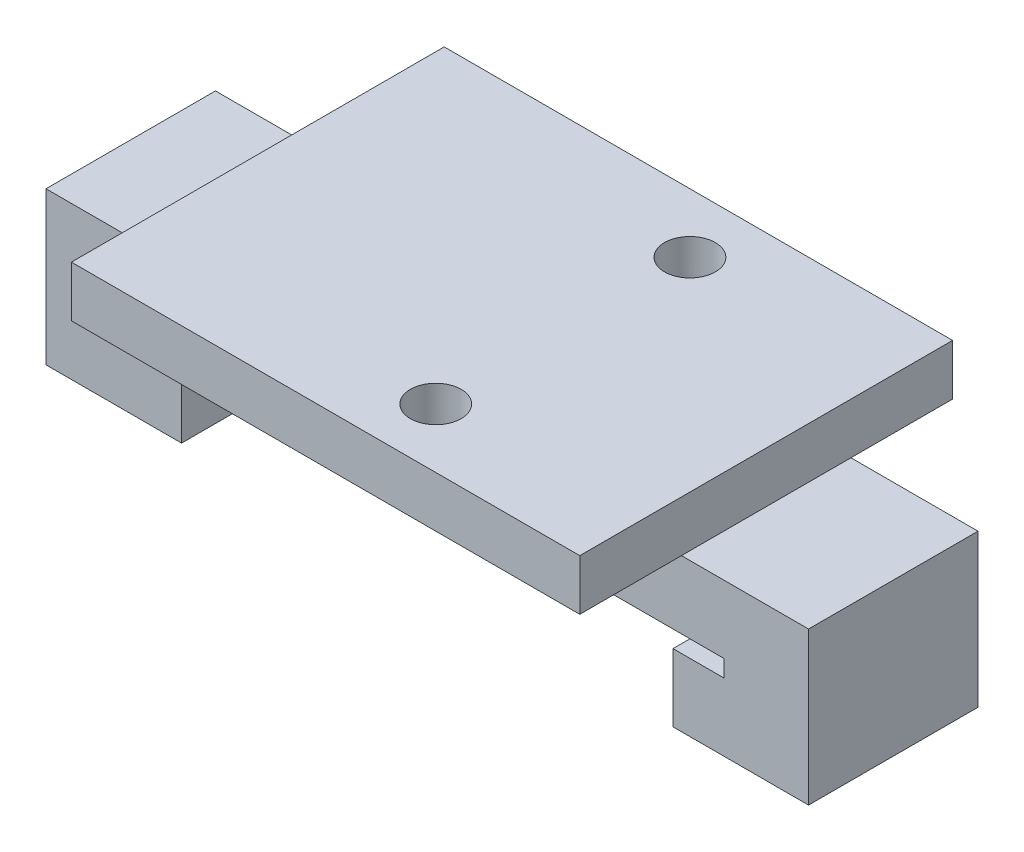
from build123d import *

# Parameters (mm, degrees)
BOSS_EXTRUDE1_DEPTH = 10
SKETCH3_W           = 30
SKETCH3_H           = 22
BOSS_EXTRUDE2_DEPTH = 3
SKETCH4_R           = 1.5
CUT_EXTRUDE1_DEPTH  = 5


with BuildPart() as part:
    # Sketch2 → Boss-Extrude1 (new body)
    with BuildSketch(Plane.XY):
        Polygon((-17.5, 0), (-17.5, -1), (-14.5, -1), (-14.5, -5), (-22.5, -5), (-22.5, 0), (-22.5, 4), (22.5, 4), (22.5, -5), (14.5, -5), (14.5, -1), (17.5, -1), (17.5, 0), align=None)
    extrude(amount=BOSS_EXTRUDE1_DEPTH)

    # Sketch3 → Boss-Extrude2 (add)
    with BuildSketch(Plane(origin=(0, 4, 0), x_dir=(1, 0, 0), z_dir=(0, 1, 0))):
        with Locations((0, -5)):
            Rectangle(SKETCH3_W, SKETCH3_H)
    extrude(amount=BOSS_EXTRUDE2_DEPTH)

    # Sketch4 → Cut-Extrude1 (cut)
    with BuildSketch(Plane(origin=(0, 7, 0), x_dir=(1, 0, 0), z_dir=(0, 1, 0))):
        with Locations((3, 2.5)):
            Circle(SKETCH4_R)
        with Locations((3, -12.5)):
            Circle(SKETCH4_R)
    extrude(amount=-CUT_EXTRUDE1_DEPTH, mode=Mode.SUBTRACT)


solid = part.part
